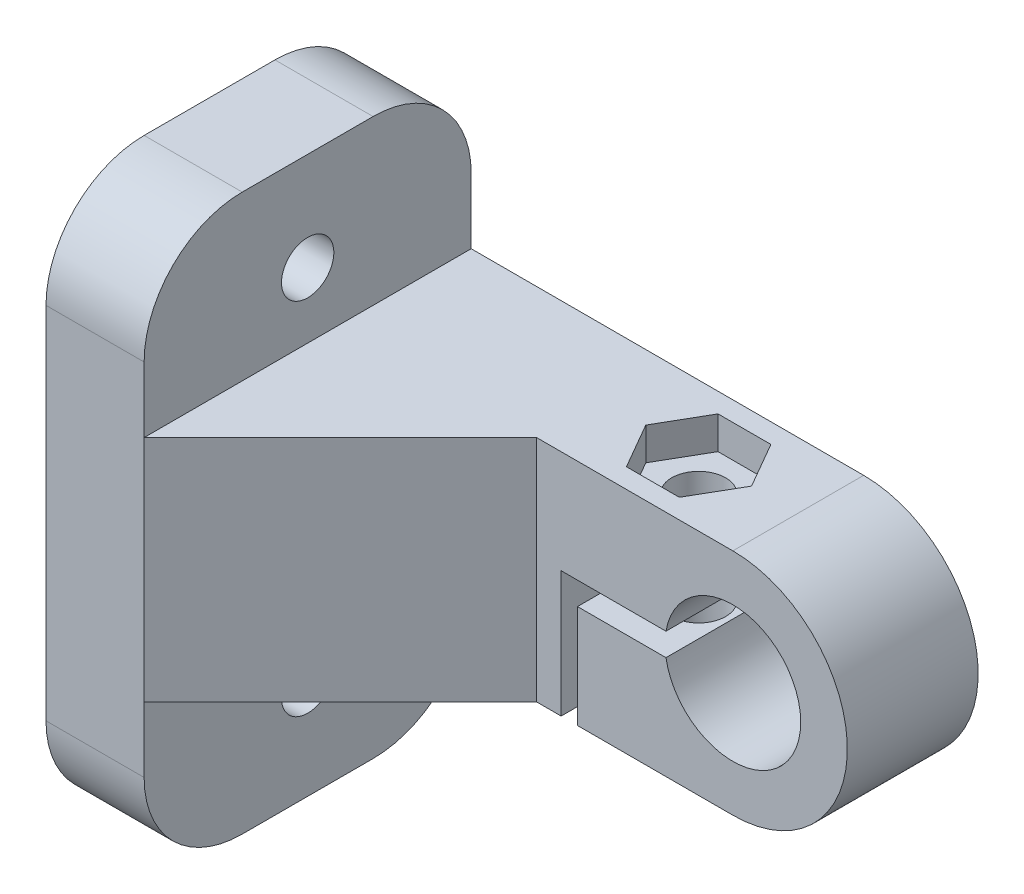
from build123d import *

# Parameters (mm, degrees)
RESSALTO_EXTRUS_O1_DEPTH   = 20
ESBO_O4_R                  = 1.6
CORTE_EXTRUS_O2_DEPTH      = 18
ESBO_O5_R                  = 5.25
CORTE_EXTRUS_O3_DEPTH      = 1
FILETE1_R                  = 6
CORTE_EXTRUS_O6_DEPTH      = 25
ESBO_O6_R                  = 1.65
CORTE_EXTRUS_O4_DEPTH      = 18.7
CORTE_EXTRUS_O4_DEPTH_BACK = 17.3
CORTE_EXTRUS_O5_DEPTH      = 2


with BuildPart() as part:
    # Esboço2 → Ressalto-extrusão1 (new body)
    with BuildSketch(Plane.XY):
        with BuildLine():
            Line((0, 7), (-24, 7))
            Line((-24, 7), (-24, 17))
            Line((-24, 17), (-30, 17))
            Line((-30, 17), (-30, -17))
            Line((-30, -17), (-24, -17))
            Line((-24, -17), (-24, -7))
            Line((-24, -7), (-10.5, -7))
            Line((-10.5, -7), (-10.5, 0.7))
            Line((-10.5, 0.7), (-4.090537862, 0.7))
            ThreePointArc((-4.090537862, 0.7), (4.15, 0), (-4.090537862, -0.7))
            Line((-4.090537862, -0.7), (-9.5, -0.7))
            Line((-9.5, -0.7), (-9.5, -7))
            Line((-9.5, -7), (0, -7))
            ThreePointArc((0, -7), (7, 0), (0, 7))
        make_face()
    extrude(amount=RESSALTO_EXTRUS_O1_DEPTH)

    # Esboço4 → Corte-extrusão2 (cut)
    with BuildSketch(Plane.ZY.offset(30)):
        with Locations((10, 11)):
            Circle(ESBO_O4_R)
        with Locations((10, -11)):
            Circle(ESBO_O4_R)
    extrude(amount=-CORTE_EXTRUS_O2_DEPTH, mode=Mode.SUBTRACT)

    # Esboço5 → Corte-extrusão3 (cut)
    with BuildSketch(Plane.ZY.offset(30)):
        with Locations((10, 11)):
            Circle(ESBO_O5_R)
        with Locations((10, -11)):
            Circle(ESBO_O5_R)
    extrude(amount=-CORTE_EXTRUS_O3_DEPTH, mode=Mode.SUBTRACT)

    # Filete1
    filete1_edges = [part.edges().sort_by_distance(p)[0] for p in [
        (-27, -17, 20),
        (-27, -17, 0),
        (-27, 17, 0),
        (-27, 17, 20),
    ]]
    fillet(filete1_edges, radius=FILETE1_R)

    # Esboço8 → Corte-extrusão6 (cut, through all)
    with BuildSketch(Plane(origin=(0, 7, 0), x_dir=(1, 0, 0), z_dir=(0, 1, 0))):
        Polygon((-24, -20), (-12, -8), (7, -8), (7, -20), align=None)
    extrude(amount=-CORTE_EXTRUS_O6_DEPTH, mode=Mode.SUBTRACT)

    # Esboço6 → Corte-extrusão4 (cut, two sides)
    with BuildSketch(Plane.XZ.offset(-0.7)) as corte_extrus_o4_sk:
        with Locations((-6.090537862, 4)):
            Circle(ESBO_O6_R)
    extrude(amount=CORTE_EXTRUS_O4_DEPTH, mode=Mode.SUBTRACT)
    extrude(corte_extrus_o4_sk.sketch, amount=-CORTE_EXTRUS_O4_DEPTH_BACK, mode=Mode.SUBTRACT)

    # Esboço7 → Corte-extrusão5 (cut)
    with BuildSketch(Plane(origin=(0, 7, 0), x_dir=(1, 0, 0), z_dir=(0, 1, 0))):
        Polygon((-2.857376354, -4), (-4.473957108, -1.2), (-7.707118616, -1.2), (-9.323699369, -4), (-7.707118616, -6.8), (-4.473957108, -6.8), align=None)
    extrude(amount=-CORTE_EXTRUS_O5_DEPTH, mode=Mode.SUBTRACT)


solid = part.part
